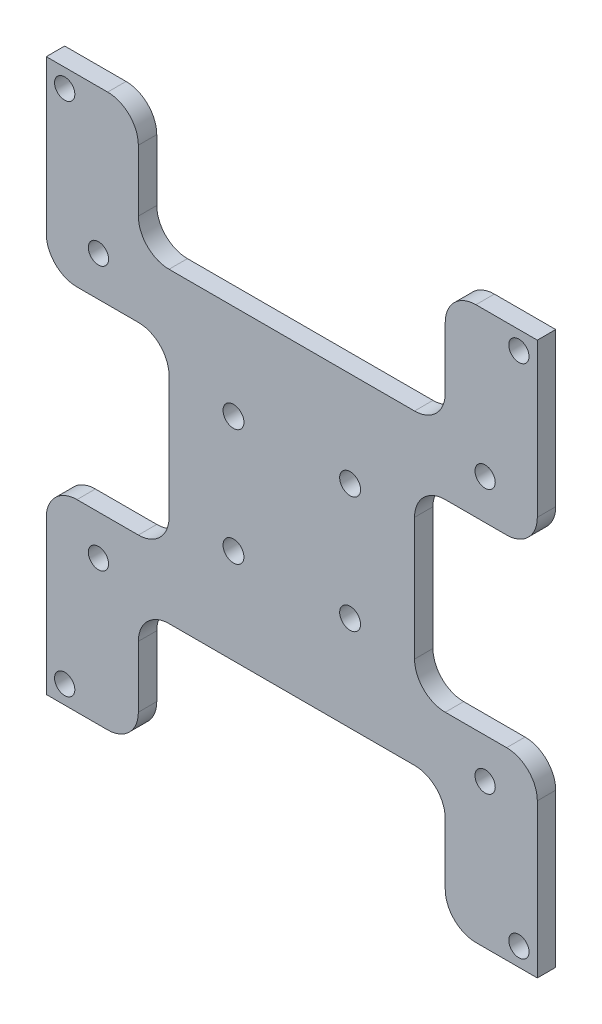
from build123d import *

# Parameters (mm, degrees)
SKETCH_1_W          = 80
SKETCH_1_H          = 90
EXTRUDE_1_DEPTH     = 3
SKETCH_2_R          = 1.65
CUT_EXTRUDE_1_DEPTH = 3
CUT_EXTRUDE_2_REACH = 5
SKETCH_3_R          = 1.65
SKETCH_3_W          = 50
SKETCH_3_H          = 20
SKETCH_3_W_2        = 20
SKETCH_3_H_2        = 30
FILLET_1_R          = 5
CUT_EXTRUDE_3_REACH = 5
SKETCH_4_R          = 1.7


with BuildPart() as part:
    # 草图1 → 凸台-拉伸1 (new body)
    with BuildSketch(Plane.XY):
        with Locations((5.850106622, 2.961375961)):
            Rectangle(SKETCH_1_W, SKETCH_1_H)
    extrude(amount=EXTRUDE_1_DEPTH)

    # 草图2 → 切除-拉伸1 (cut)
    with BuildSketch(Plane(origin=(0, 0, 0), x_dir=(-1, 0, 0), z_dir=(0, 0, -1))):
        with Locations((31.149893378, -39.038624039)):
            Circle(SKETCH_2_R)
        with Locations((-42.850106622, -39.038624039)):
            Circle(SKETCH_2_R)
        with Locations((31.149893378, 44.961375961)):
            Circle(SKETCH_2_R)
        with Locations((-42.850106622, 44.961375961)):
            Circle(SKETCH_2_R)
    extrude(amount=-CUT_EXTRUDE_1_DEPTH, mode=Mode.SUBTRACT)

    # 草图3 → 切除-拉伸2 (cut, up to next)
    with BuildSketch(Plane(origin=(0, 0, 0), x_dir=(-1, 0, 0), z_dir=(0, 0, -1)), mode=Mode.PRIVATE) as cut_extrude_2_sk1:
        with Locations((-37.350106622, 24.461375961)):
            Circle(SKETCH_3_R)
    cut_extrude_2_tool1 = extrude(cut_extrude_2_sk1.sketch, amount=-CUT_EXTRUDE_2_REACH, mode=Mode.PRIVATE) & part.part
    add(cut_extrude_2_tool1.solids().sort_by_distance((37.350107, 24.461376, 0))[0], mode=Mode.SUBTRACT)
    # 草图3 → 切除-拉伸2 (cut, up to next)
    with BuildSketch(Plane(origin=(0, 0, 0), x_dir=(-1, 0, 0), z_dir=(0, 0, -1)), mode=Mode.PRIVATE) as cut_extrude_2_sk2:
        with Locations((25.649893378, 24.461375961)):
            Circle(SKETCH_3_R)
    cut_extrude_2_tool2 = extrude(cut_extrude_2_sk2.sketch, amount=-CUT_EXTRUDE_2_REACH, mode=Mode.PRIVATE) & part.part
    add(cut_extrude_2_tool2.solids().sort_by_distance((-25.649893, 24.461376, 0))[0], mode=Mode.SUBTRACT)
    # 草图3 → 切除-拉伸2 (cut, up to next)
    with BuildSketch(Plane(origin=(0, 0, 0), x_dir=(-1, 0, 0), z_dir=(0, 0, -1)), mode=Mode.PRIVATE) as cut_extrude_2_sk3:
        with Locations((25.649893378, -18.538624039)):
            Circle(SKETCH_3_R)
    cut_extrude_2_tool3 = extrude(cut_extrude_2_sk3.sketch, amount=-CUT_EXTRUDE_2_REACH, mode=Mode.PRIVATE) & part.part
    add(cut_extrude_2_tool3.solids().sort_by_distance((-25.649893, -18.538624, 0))[0], mode=Mode.SUBTRACT)
    # 草图3 → 切除-拉伸2 (cut, up to next)
    with BuildSketch(Plane(origin=(0, 0, 0), x_dir=(-1, 0, 0), z_dir=(0, 0, -1)), mode=Mode.PRIVATE) as cut_extrude_2_sk4:
        with Locations((-37.350106622, -18.538624039)):
            Circle(SKETCH_3_R)
    cut_extrude_2_tool4 = extrude(cut_extrude_2_sk4.sketch, amount=-CUT_EXTRUDE_2_REACH, mode=Mode.PRIVATE) & part.part
    add(cut_extrude_2_tool4.solids().sort_by_distance((37.350107, -18.538624, 0))[0], mode=Mode.SUBTRACT)
    # 草图3 → 切除-拉伸2 (cut, up to next)
    with BuildSketch(Plane(origin=(0, 0, 0), x_dir=(-1, 0, 0), z_dir=(0, 0, -1)), mode=Mode.PRIVATE) as cut_extrude_2_sk5:
        with Locations((-5.850106622, 37.961375961)):
            Rectangle(SKETCH_3_W, SKETCH_3_H)
    cut_extrude_2_tool5 = extrude(cut_extrude_2_sk5.sketch, amount=-CUT_EXTRUDE_2_REACH, mode=Mode.PRIVATE) & part.part
    add(cut_extrude_2_tool5.solids().sort_by_distance((5.850107, 37.961376, 0))[0], mode=Mode.SUBTRACT)
    # 草图3 → 切除-拉伸2 (cut, up to next)
    with BuildSketch(Plane(origin=(0, 0, 0), x_dir=(-1, 0, 0), z_dir=(0, 0, -1)), mode=Mode.PRIVATE) as cut_extrude_2_sk6:
        with Locations((-5.850106622, -32.038624039)):
            Rectangle(SKETCH_3_W, SKETCH_3_H)
    cut_extrude_2_tool6 = extrude(cut_extrude_2_sk6.sketch, amount=-CUT_EXTRUDE_2_REACH, mode=Mode.PRIVATE) & part.part
    add(cut_extrude_2_tool6.solids().sort_by_distance((5.850107, -32.038624, 0))[0], mode=Mode.SUBTRACT)
    # 草图3 → 切除-拉伸2 (cut, up to next)
    with BuildSketch(Plane(origin=(0, 0, 0), x_dir=(-1, 0, 0), z_dir=(0, 0, -1)), mode=Mode.PRIVATE) as cut_extrude_2_sk7:
        with Locations((24.149893378, 2.961375961)):
            Rectangle(SKETCH_3_W_2, SKETCH_3_H_2)
    cut_extrude_2_tool7 = extrude(cut_extrude_2_sk7.sketch, amount=-CUT_EXTRUDE_2_REACH, mode=Mode.PRIVATE) & part.part
    add(cut_extrude_2_tool7.solids().sort_by_distance((-24.149893, 2.961376, 0))[0], mode=Mode.SUBTRACT)
    # 草图3 → 切除-拉伸2 (cut, up to next)
    with BuildSketch(Plane(origin=(0, 0, 0), x_dir=(-1, 0, 0), z_dir=(0, 0, -1)), mode=Mode.PRIVATE) as cut_extrude_2_sk8:
        with Locations((-35.850106622, 2.961375961)):
            Rectangle(SKETCH_3_W_2, SKETCH_3_H_2)
    cut_extrude_2_tool8 = extrude(cut_extrude_2_sk8.sketch, amount=-CUT_EXTRUDE_2_REACH, mode=Mode.PRIVATE) & part.part
    add(cut_extrude_2_tool8.solids().sort_by_distance((35.850107, 2.961376, 0))[0], mode=Mode.SUBTRACT)

    # 圆角1
    fillet_1_edges = [part.edges().sort_by_distance(p)[0] for p in [
        (30.850106622, 47.961375961, 1.5),
        (-19.149893378, 47.961375961, 1.5),
        (-19.149893378, 27.961375961, 1.5),
        (30.850106622, 27.961375961, 1.5),
        (45.850106622, -12.038624039, 1.5),
        (45.850106622, 17.961375961, 1.5),
        (25.850106622, 17.961375961, 1.5),
        (25.850106622, -12.038624039, 1.5),
        (-14.149893378, 17.961375961, 1.5),
        (-34.149893378, 17.961375961, 1.5),
        (-34.149893378, -12.038624039, 1.5),
        (-14.149893378, -12.038624039, 1.5),
        (30.850106622, -22.038624039, 1.5),
        (-19.149893378, -22.038624039, 1.5),
        (-19.149893378, -42.038624039, 1.5),
        (30.850106622, -42.038624039, 1.5),
    ]]
    fillet(fillet_1_edges, radius=FILLET_1_R)

    # 草图4 → 切除-拉伸3 (cut, up to next)
    with BuildSketch(Plane(origin=(0, 0, 0), x_dir=(-1, 0, 0), z_dir=(0, 0, -1)), mode=Mode.PRIVATE) as cut_extrude_3_sk1:
        with Locations((3.649893378, 12.461375961)):
            Circle(SKETCH_4_R)
    cut_extrude_3_tool1 = extrude(cut_extrude_3_sk1.sketch, amount=-CUT_EXTRUDE_3_REACH, mode=Mode.PRIVATE) & part.part
    add(cut_extrude_3_tool1.solids().sort_by_distance((-3.649893, 12.461376, 0))[0], mode=Mode.SUBTRACT)
    # 草图4 → 切除-拉伸3 (cut, up to next)
    with BuildSketch(Plane(origin=(0, 0, 0), x_dir=(-1, 0, 0), z_dir=(0, 0, -1)), mode=Mode.PRIVATE) as cut_extrude_3_sk2:
        with Locations((3.649893378, -6.538624039)):
            Circle(SKETCH_4_R)
    cut_extrude_3_tool2 = extrude(cut_extrude_3_sk2.sketch, amount=-CUT_EXTRUDE_3_REACH, mode=Mode.PRIVATE) & part.part
    add(cut_extrude_3_tool2.solids().sort_by_distance((-3.649893, -6.538624, 0))[0], mode=Mode.SUBTRACT)
    # 草图4 → 切除-拉伸3 (cut, up to next)
    with BuildSketch(Plane(origin=(0, 0, 0), x_dir=(-1, 0, 0), z_dir=(0, 0, -1)), mode=Mode.PRIVATE) as cut_extrude_3_sk3:
        with Locations((-15.350106622, -6.538624039)):
            Circle(SKETCH_4_R)
    cut_extrude_3_tool3 = extrude(cut_extrude_3_sk3.sketch, amount=-CUT_EXTRUDE_3_REACH, mode=Mode.PRIVATE) & part.part
    add(cut_extrude_3_tool3.solids().sort_by_distance((15.350107, -6.538624, 0))[0], mode=Mode.SUBTRACT)
    # 草图4 → 切除-拉伸3 (cut, up to next)
    with BuildSketch(Plane(origin=(0, 0, 0), x_dir=(-1, 0, 0), z_dir=(0, 0, -1)), mode=Mode.PRIVATE) as cut_extrude_3_sk4:
        with Locations((-15.350106622, 12.461375961)):
            Circle(SKETCH_4_R)
    cut_extrude_3_tool4 = extrude(cut_extrude_3_sk4.sketch, amount=-CUT_EXTRUDE_3_REACH, mode=Mode.PRIVATE) & part.part
    add(cut_extrude_3_tool4.solids().sort_by_distance((15.350107, 12.461376, 0))[0], mode=Mode.SUBTRACT)


solid = part.part
